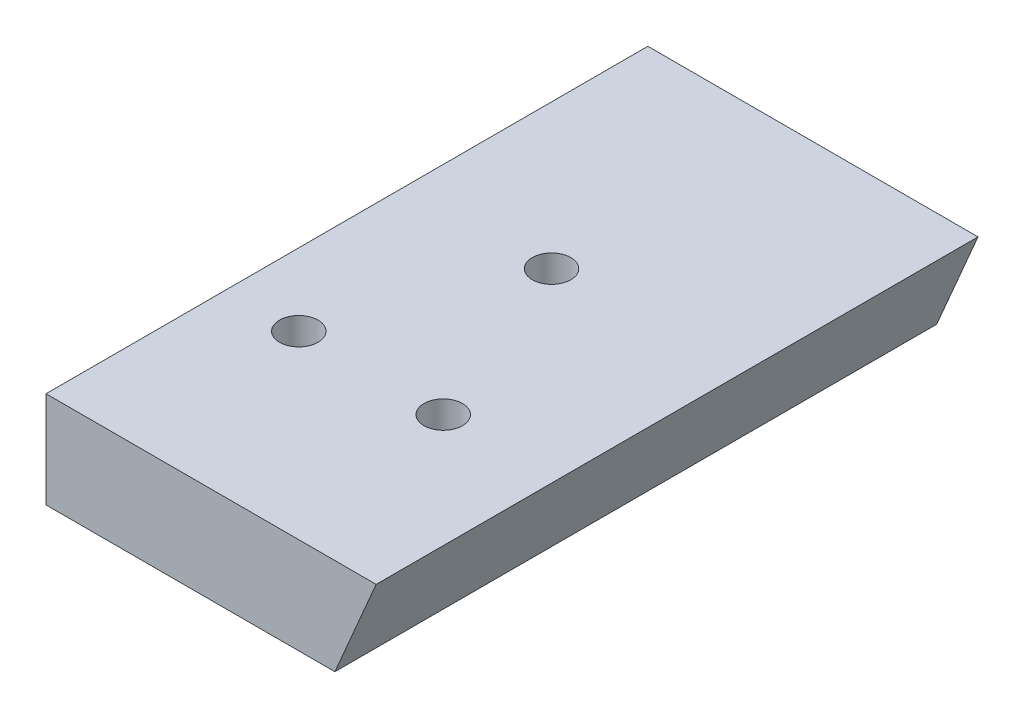
from build123d import *

# Parameters (mm, degrees)
SALIENTE_EXTRUIR1_DEPTH = 50
CORTAR_EXTRUIR1_REACH   = 10
CROQUIS3_R              = 1.6
CROQUIS6_R              = 1.9
CORTAR_EXTRUIR3_DEPTH   = 10


with BuildPart() as part:
    # Croquis1 → Saliente-Extruir1 (new body)
    with BuildSketch(Plane.XY):
        Polygon((45.761533754, 80.324875029), (73.190105182, 80.324875029), (69.761533754, 72.324875029), (45.761533754, 72.324875029), align=None)
    extrude(amount=SALIENTE_EXTRUIR1_DEPTH)

    # Croquis3 → Cortar-Extruir1 (cut, up to next)
    with BuildSketch(Plane.XZ.offset(-72.324875029), mode=Mode.PRIVATE) as cortar_extruir1_sk1:
        with Locations((63.761533754, 35)):
            Circle(CROQUIS3_R)
    cortar_extruir1_tool1 = extrude(cortar_extruir1_sk1.sketch, amount=-CORTAR_EXTRUIR1_REACH, mode=Mode.PRIVATE) & part.part
    add(cortar_extruir1_tool1.solids().sort_by_distance((63.761534, 72.324875, 35))[0], mode=Mode.SUBTRACT)
    # Croquis3 → Cortar-Extruir1 (cut, up to next)
    with BuildSketch(Plane.XZ.offset(-72.324875029), mode=Mode.PRIVATE) as cortar_extruir1_sk2:
        with Locations((57.761533754, 20)):
            Circle(CROQUIS3_R)
    cortar_extruir1_tool2 = extrude(cortar_extruir1_sk2.sketch, amount=-CORTAR_EXTRUIR1_REACH, mode=Mode.PRIVATE) & part.part
    add(cortar_extruir1_tool2.solids().sort_by_distance((57.761534, 72.324875, 20))[0], mode=Mode.SUBTRACT)
    # Croquis3 → Cortar-Extruir1 (cut, up to next)
    with BuildSketch(Plane.XZ.offset(-72.324875029), mode=Mode.PRIVATE) as cortar_extruir1_sk3:
        with Locations((51.761533754, 35)):
            Circle(CROQUIS3_R)
    cortar_extruir1_tool3 = extrude(cortar_extruir1_sk3.sketch, amount=-CORTAR_EXTRUIR1_REACH, mode=Mode.PRIVATE) & part.part
    add(cortar_extruir1_tool3.solids().sort_by_distance((51.761534, 72.324875, 35))[0], mode=Mode.SUBTRACT)

    # Croquis6 → Cortar-Extruir3 (cut)
    with BuildSketch(Plane(origin=(0, 0, 0), x_dir=(-1, 0, 0), z_dir=(0, 0, -1))):
        with Locations((-66.332962325, 76.324875029)):
            Circle(CROQUIS6_R)
        with Locations((-52.618676611, 76.324875029)):
            Circle(CROQUIS6_R)
    extrude(amount=-CORTAR_EXTRUIR3_DEPTH, mode=Mode.SUBTRACT)


solid = part.part
